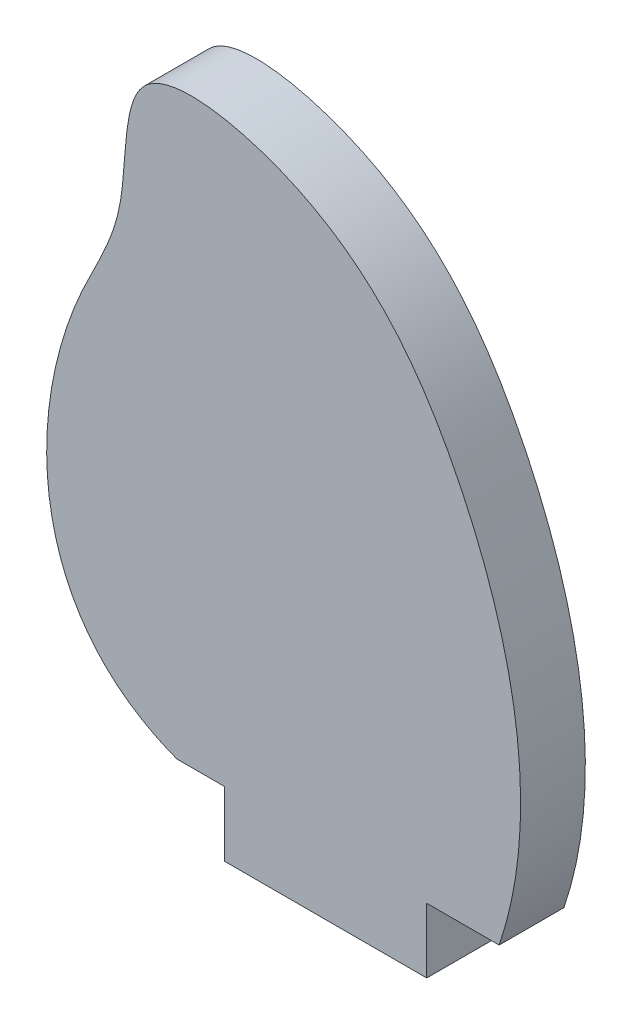
from build123d import *

# Parameters (mm, degrees)
BOSS_EXTRUDE1_DEPTH = 3.2


with BuildPart() as part:
    # Sketch1 → Boss-Extrude1 (new body)
    with BuildSketch(Plane.XY):
        with BuildLine():
            Line((0, 0), (-2.348176738, 0))
            add(Edge.make_bspline(
                [(-2.348176738, 0), (-9.964854367, 2.867219736), (-9.793130478, 13.670052179), (-4.526532464, 22.122463184), (-5.433811762, 29.716998895), (5.694969977, 27.8152859), (13.485488092, 17.76722066), (15.768521288, 6.460257665), (13.580872951, 0)],
                knots=[0, 0, 0, 0, 0.289811066, 0.359114505, 0.444366481, 0.539446433, 0.714050212, 1, 1, 1, 1], degree=3))
            Line((13.580872951, 0), (10, 0))
            Line((10, 0), (10, -3.2))
            Line((10, -3.2), (0, -3.2))
            Line((0, -3.2), (0, 0))
        make_face()
    extrude(amount=BOSS_EXTRUDE1_DEPTH)


solid = part.part
